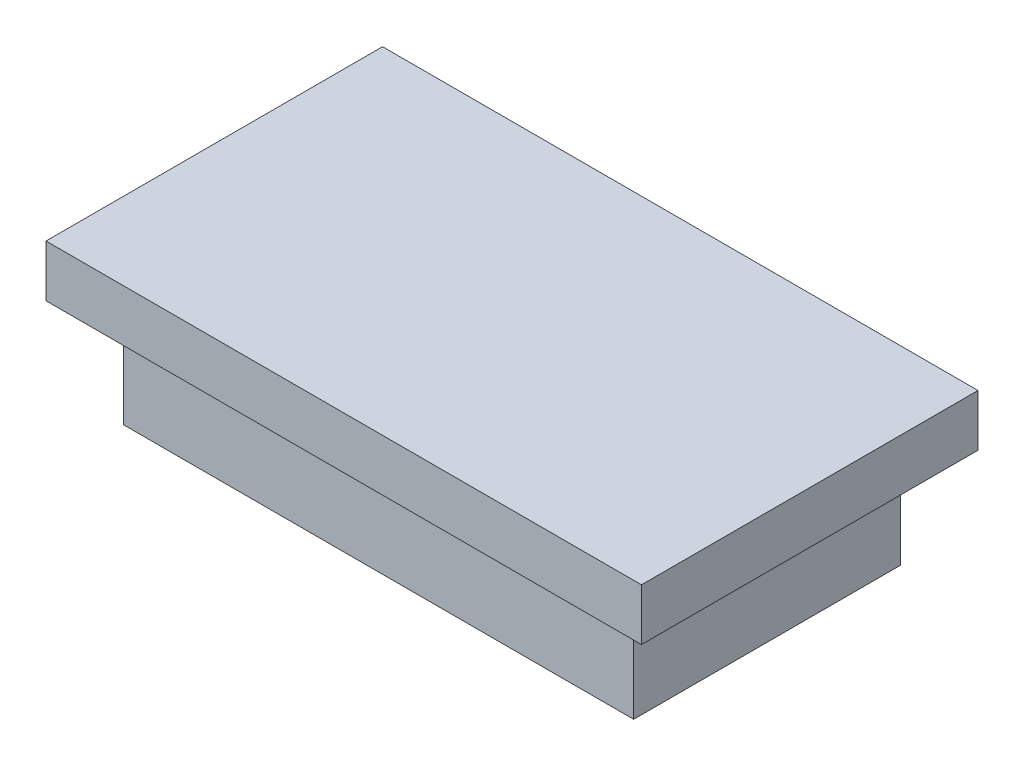
from build123d import *

# Parameters (mm, degrees)
SKETCH1_W           = 19.7
SKETCH1_H           = 10.3
BOSS_EXTRUDE1_DEPTH = 4
SKETCH2_W           = 23
SKETCH2_H           = 13
BOSS_EXTRUDE2_DEPTH = 2


with BuildPart() as part:
    # Sketch1 → Boss-Extrude1 (new body)
    with BuildSketch(Plane(origin=(0, 0, 0), x_dir=(1, 0, 0), z_dir=(0, 1, 0))):
        Rectangle(SKETCH1_W, SKETCH1_H)
    extrude(amount=BOSS_EXTRUDE1_DEPTH)

    # Sketch2 → Boss-Extrude2 (add)
    with BuildSketch(Plane(origin=(0, 4, 0), x_dir=(1, 0, 0), z_dir=(0, 1, 0))):
        Rectangle(SKETCH2_W, SKETCH2_H)
    extrude(amount=BOSS_EXTRUDE2_DEPTH)


solid = part.part
